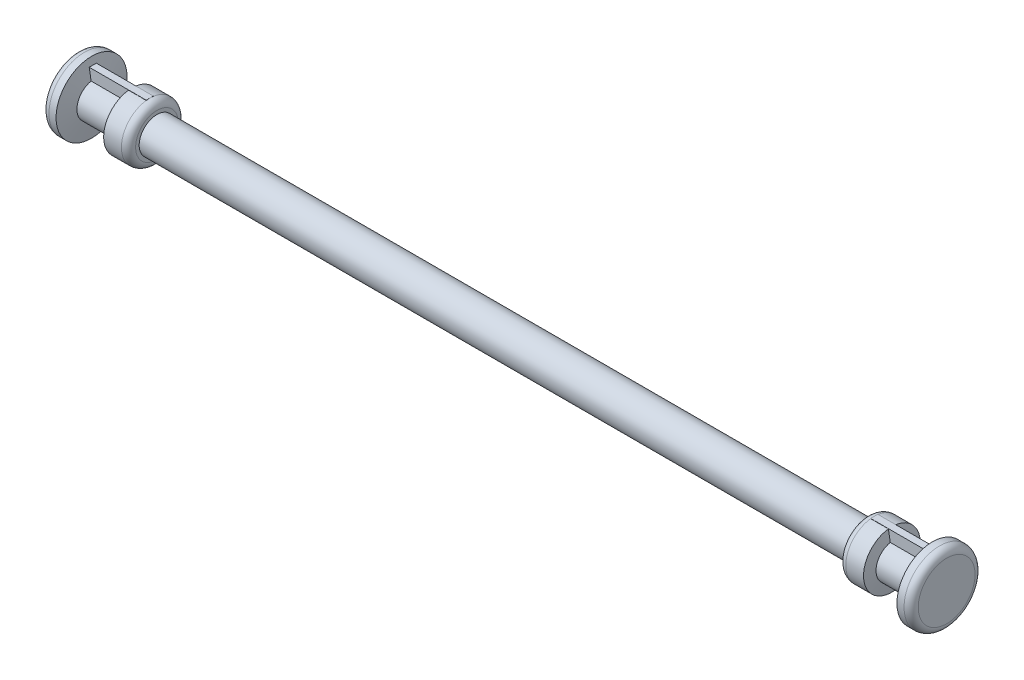
from build123d import *

# Parameters (mm, degrees)
SKETCH3_W           = 2
SKETCH3_H           = 8.955152332
BOSS_EXTRUDE1_DEPTH = 20
SKETCH4_W           = 2
SKETCH4_H           = 8
BOSS_EXTRUDE2_DEPTH = 19
FILLET1_R           = 2
BOSS_EXTRUDE4_START = -0.065389
SKETCH6_W           = 1.410615846
SKETCH6_H           = 2.020756053
BOSS_EXTRUDE4_DEPTH = 0.065389
BOSS_EXTRUDE5_REACH = 20
SKETCH7_W           = 0.410615846
SKETCH7_H           = 2.003452902


with BuildPart() as part:
    # Sketch2 → Revolve2 (revolve)
    with BuildSketch(Plane.XY):
        Polygon((100, 3), (100, 0), (-100, 0), (-100, 3), (-107, 3), (-107.528980942, 0), (-117.528980942, 0), (-118.410615846, 5), (-122.410615846, 5), (-122.410615846, -5), (122.410615846, -5), (122.410615846, 5), (118.410615846, 5), (117.528980942, 0), (107.528980942, 0), (107, 3), align=None)
    revolve(axis=Axis((-122.410615846, -5, 0), (1, 0, 0)))

    # Sketch3 → Boss-Extrude1 (add)
    with BuildSketch(Plane(origin=(122.410615846, 0, 0), x_dir=(0, 0, -1), z_dir=(1, 0, 0))):
        with Locations((0, -1.477576166)):
            Rectangle(SKETCH3_W, SKETCH3_H)
    extrude(amount=-BOSS_EXTRUDE1_DEPTH)

    # Sketch4 → Boss-Extrude2 (add)
    with BuildSketch(Plane.ZY.offset(122.410615846)):
        with Locations((0, -1)):
            Rectangle(SKETCH4_W, SKETCH4_H)
    extrude(amount=-BOSS_EXTRUDE2_DEPTH)

    # Fillet1
    fillet1_edges = [part.edges().sort_by_distance(p)[0] for p in [
        (-122.410615846, -15, 0),
        (-100, -13, 0),
        (100, -13, 0),
        (122.410615846, -15, 0),
    ]]
    fillet(fillet1_edges, radius=FILLET1_R)

    # Sketch6 → Boss-Extrude4 (add)
    with BuildSketch(Plane(origin=(0, 3, 0), x_dir=(1, 0, 0), z_dir=(0, 1, 0)).offset(BOSS_EXTRUDE4_START)):
        with Locations((-102.705307923, -0.010378027)):
            Rectangle(SKETCH6_W, SKETCH6_H)
    extrude(amount=BOSS_EXTRUDE4_DEPTH)

    # Sketch7 → Boss-Extrude5 (add, up to next)
    with BuildSketch(Plane(origin=(0, 3, 0), x_dir=(1, 0, 0), z_dir=(0, 1, 0)), mode=Mode.PRIVATE) as boss_extrude5_sk1:
        with Locations((102.205307923, -0.001726451)):
            Rectangle(SKETCH7_W, SKETCH7_H)
    boss_extrude5_tool1 = extrude(boss_extrude5_sk1.sketch, amount=-BOSS_EXTRUDE5_REACH, mode=Mode.PRIVATE) - part.part
    add(boss_extrude5_tool1.solids().sort_by_distance((102.205308, 3, 0.001726))[0])
    add(boss_extrude5_tool1.solids().sort_by_distance((102.205308, 3, 0.001726))[1])


solid = part.part
